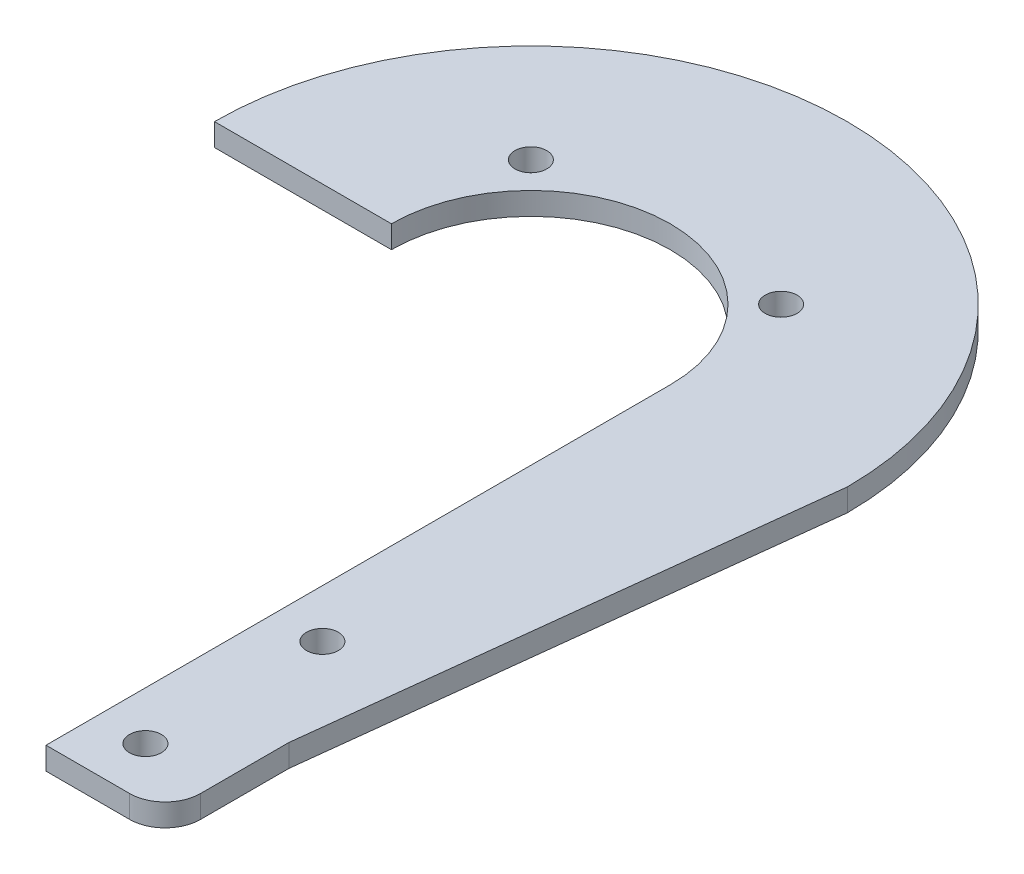
from build123d import *

# Parameters (mm, degrees)
SKETCH2_R           = 2.25
BOSS_EXTRUDE1_DEPTH = 3.175


with BuildPart() as part:
    # Sketch2 → Boss-Extrude1 (new body)
    with BuildSketch(Plane(origin=(0, 0, 0), x_dir=(1, 0, 0), z_dir=(0, 1, 0))):
        with BuildLine():
            Line((19.7, -88.2), (31.525, -88.2))
            ThreePointArc((31.525, -88.2), (35.060533906, -86.735533906), (36.525, -83.2))
            Line((36.525, -83.2), (36.525, -70.7))
            Line((36.525, -70.7), (44.7, 0))
            ThreePointArc((44.7, 0), (0, 44.7), (-44.7, 0))
            Line((-44.7, 0), (-19.7, 0))
            ThreePointArc((-19.7, 0), (0, 19.7), (19.7, 0))
            Line((19.7, 0), (19.7, -88.2))
        make_face()
        with Locations((26.525, -80.975)):
            Circle(SKETCH2_R, mode=Mode.SUBTRACT)
        with Locations((26.525, -55.975)):
            Circle(SKETCH2_R, mode=Mode.SUBTRACT)
        with Locations((-17.67766953, 17.67766953)):
            Circle(SKETCH2_R, mode=Mode.SUBTRACT)
        with Locations((17.67766953, 17.67766953)):
            Circle(SKETCH2_R, mode=Mode.SUBTRACT)
    extrude(amount=BOSS_EXTRUDE1_DEPTH)


solid = part.part
